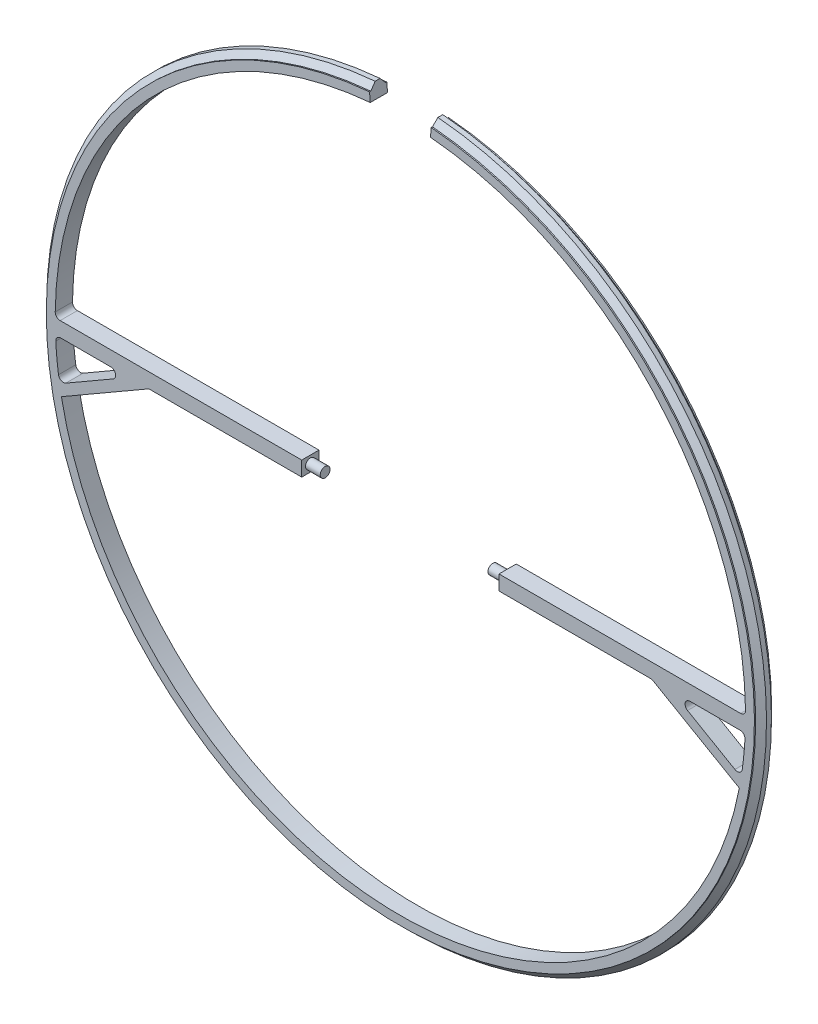
from build123d import *

# Parameters (mm, degrees)
REVOLVE1_ANGLE           = 175
REVOLVE1_OTHER_WAY_ANGLE = 175
BOSS_EXTRUDE1_DEPTH      = 1.75
SKETCH5_R                = 1
BOSS_EXTRUDE2_DEPTH      = 3
FILLET1_R                = 1
FILLET1_OF_MIRROR1_R     = 1


with BuildPart() as part:
    # Sketch2 → Revolve1 (revolve)
    with BuildSketch(Plane(origin=(0, 0, 0), x_dir=(0, 0, -1), z_dir=(1, 0, 0))):
        Polygon((1.75, -70), (1.75, -71.8), (1.5, -71.8), (0.5, -73), (-0.5, -73), (-1.5, -71.8), (-1.75, -71.8), (-1.75, -70), align=None)
    revolve(axis=Axis((0, 0, 0), (0, 0, -1)), revolution_arc=REVOLVE1_ANGLE)

    # Sketch2 → Revolve1 other way (revolve)
    with BuildSketch(Plane(origin=(0, 0, 0), x_dir=(0, 0, -1), z_dir=(1, 0, 0))):
        Polygon((1.75, -70), (1.75, -71.8), (1.5, -71.8), (0.5, -73), (-0.5, -73), (-1.5, -71.8), (-1.75, -71.8), (-1.75, -70), align=None)
    revolve(axis=Axis((0, 0, 0), (0, 0, 1)), revolution_arc=REVOLVE1_OTHER_WAY_ANGLE)

    # Sketch3 → Boss-Extrude1 (add, symmetric)
    with BuildSketch(Plane.XY):
        Polygon((-70, 0), (-20, 0), (-20, -3), (-51, -3), (-68.736443607, -13.240140491), (-69.736443607, -11.508089684), (-55, -3), (-70, -3), align=None)
    boss_extrude1 = extrude(amount=BOSS_EXTRUDE1_DEPTH, both=True)

    # Sketch5 → Boss-Extrude2 (add)
    with BuildSketch(Plane(origin=(-20, 0, 0), x_dir=(0, 0, -1), z_dir=(1, 0, 0))):
        with Locations((0, -1.5)):
            Circle(SKETCH5_R)
    boss_extrude2 = extrude(amount=BOSS_EXTRUDE2_DEPTH)

    # Fillet1
    fillet1_edges = [part.edges().sort_by_distance(p)[0] for p in [
        (-69.93568474, -3, 0),
        (-69.107123463, -11.144751529, 0),
        (-70, 0, 0),
        (-55, -3, 0),
        (-51, -3, 0),
    ]]
    fillet(fillet1_edges, radius=FILLET1_R)

    # Mirror1: Boss-Extrude1, Boss-Extrude2 across plane
    add(boss_extrude1.mirror(Plane(origin=(0, 0, 0), x_dir=(0, 0, 1), z_dir=(1, 0, 0))))
    add(boss_extrude2.mirror(Plane(origin=(0, 0, 0), x_dir=(0, 0, 1), z_dir=(1, 0, 0))))

    # Fillet1 of Mirror1
    fillet1_of_mirror1_edges = [part.edges().sort_by_distance(p)[0] for p in [
        (69.93568474, -3, 0),
        (69.107123463, -11.144751529, 0),
        (70, 0, 0),
        (55, -3, 0),
        (51, -3, 0),
    ]]
    fillet(fillet1_of_mirror1_edges, radius=FILLET1_OF_MIRROR1_R)


solid = part.part
